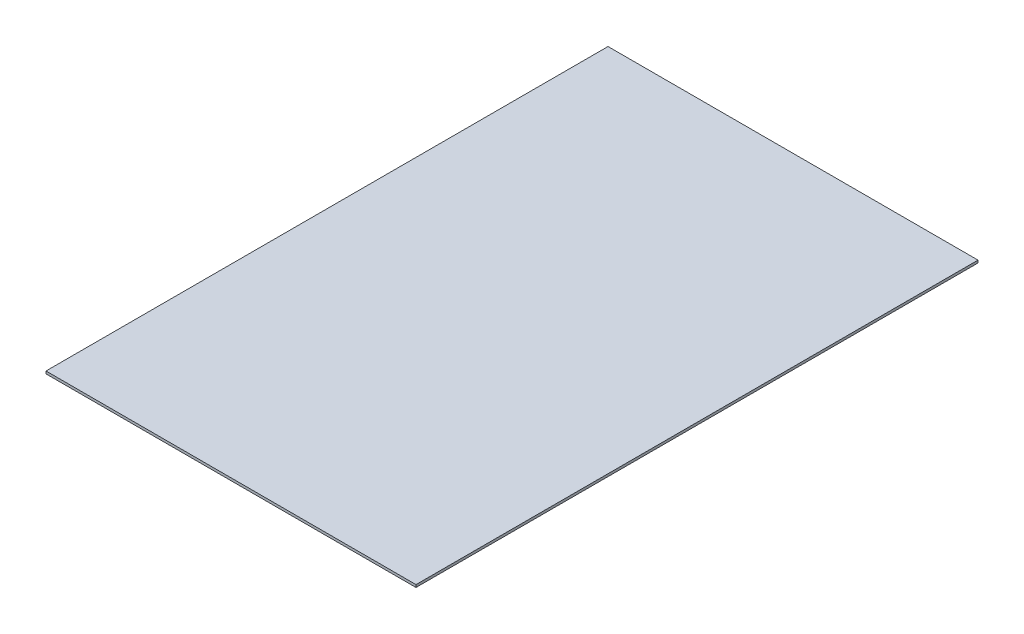
from build123d import *

# Parameters (mm, degrees)
SKETCH1_W           = 440
SKETCH1_H           = 668.38
BOSS_EXTRUDE1_DEPTH = 3


with BuildPart() as part:
    # Sketch1 → Boss-Extrude1 (new body)
    with BuildSketch(Plane(origin=(0, 0, 0), x_dir=(1, 0, 0), z_dir=(0, 1, 0))):
        with Locations((220, 334.19)):
            Rectangle(SKETCH1_W, SKETCH1_H)
    extrude(amount=BOSS_EXTRUDE1_DEPTH)


solid = part.part
